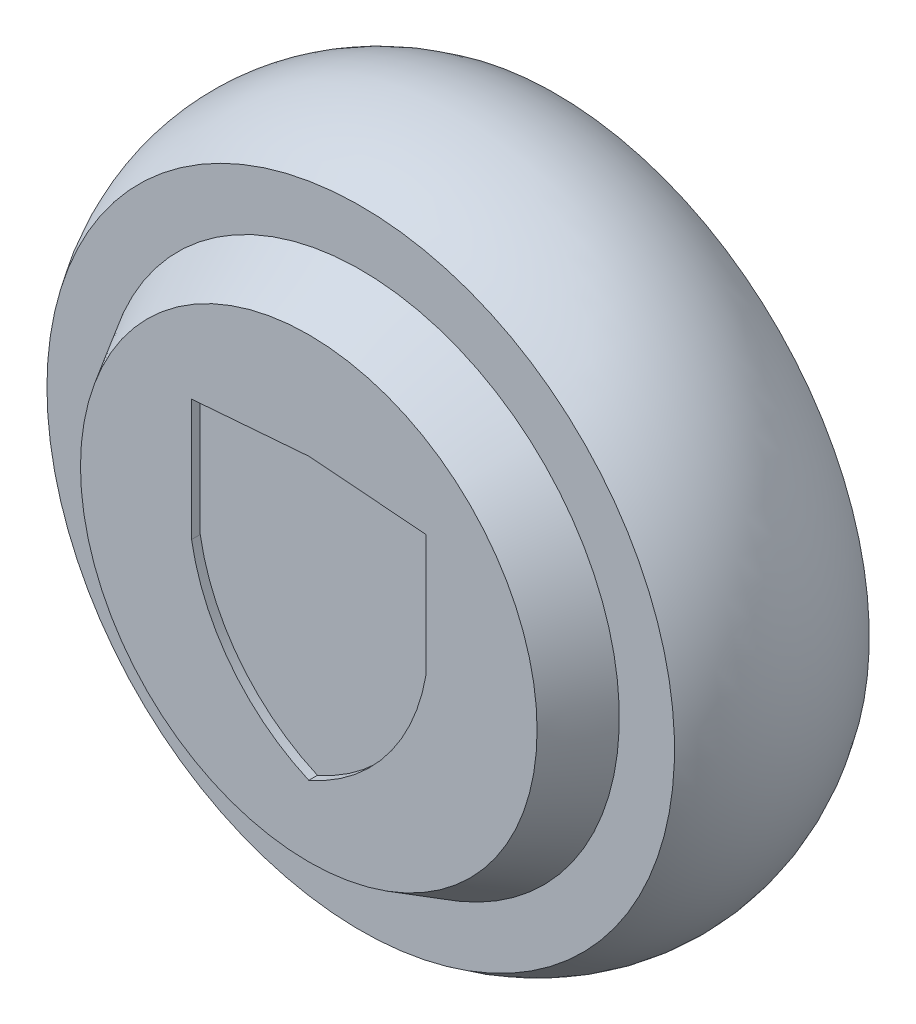
from build123d import *

# Parameters (mm, degrees)
EXTRUDE_1_DEPTH      = 22.5
EXTRUDE_1_DEPTH_BACK = 22.5
SKETCH_1_R           = 82.5
SKETCH_4_R           = 67.5
CUT_EXTRUDE_1_DEPTH  = 4
SKETCH_5_R           = 52
CUT_EXTRUDE_2_DEPTH  = 48
CUT_EXTRUDE_3_DEPTH  = 2


with BuildPart() as part:
    # Эскиз1 → Бобышка-Вытянуть1 (new, two sides: drawn at the far end of the back side and taken through both)
    with BuildSketch(Plane.XY.offset(-EXTRUDE_1_DEPTH_BACK)):
        Circle(SKETCH_1_R)
    extrude(amount=EXTRUDE_1_DEPTH + EXTRUDE_1_DEPTH_BACK)

    # Эскиз3 → Повернуть1 (revolve)
    with BuildSketch(Plane(origin=(0, 0, 0), x_dir=(0, 0, -1), z_dir=(1, 0, 0))):
        Polygon((-22.5, 0), (-22.5, 59.75), (-34.5, 52.75), (-34.5, 0), align=None)
    revolve(axis=Axis((0, 0, -22.110804518), (0, 0, 1)))

    # Эскиз4 → Вырез-Вытянуть1 (cut)
    with BuildSketch(Plane(origin=(0, 0, -22.5), x_dir=(-1, 0, 0), z_dir=(0, 0, -1))):
        Circle(SKETCH_4_R)
    extrude(amount=-CUT_EXTRUDE_1_DEPTH, mode=Mode.SUBTRACT)

    # Эскиз5 → Вырез-Вытянуть2 (cut)
    with BuildSketch(Plane(origin=(0, 0, -18.5), x_dir=(-1, 0, 0), z_dir=(0, 0, -1))):
        Circle(SKETCH_5_R)
    extrude(amount=-CUT_EXTRUDE_2_DEPTH, mode=Mode.SUBTRACT)

    # Эскиз7 → Вырез-Повернуть1 (revolve, cut)
    with BuildSketch(Plane(origin=(0, 0, 0), x_dir=(0, 0, -1), z_dir=(1, 0, 0))):
        with BuildLine():
            Line((-22.5, 72.5), (-31.948658462, 72.5))
            Line((-31.948658462, 72.5), (-31.948658462, 102.607455118))
            Line((-31.948658462, 102.607455118), (33.489916399, 102.607455118))
            Line((33.489916399, 102.607455118), (33.489916399, 72.5))
            Line((33.489916399, 72.5), (22.5, 72.5))
            ThreePointArc((22.5, 72.5), (0, 79.75), (-22.5, 72.5))
        make_face()
    revolve(axis=Axis((0, 0, 0), (0, 0, 1)), mode=Mode.SUBTRACT)

    # Эскиз8 → Вырез-Вытянуть3 (cut)
    with BuildSketch(Plane.XY.offset(34.5)):
        with BuildLine():
            Line((-27.080041081, 26.318414926), (0, 28.434043135))
            Line((0, 28.434043135), (27.080041081, 26.318414926))
            Line((27.080041081, 26.318414926), (27.080041081, -1.78158165))
            ThreePointArc((27.080041081, -1.78158165), (17.912944533, -22.517713966), (0, -36.415528927))
            ThreePointArc((0, -36.415528927), (-17.912944533, -22.517713966), (-27.080041081, -1.78158165))
            Line((-27.080041081, -1.78158165), (-27.080041081, 26.318414926))
        make_face()
    extrude(amount=-CUT_EXTRUDE_3_DEPTH, mode=Mode.SUBTRACT)


solid = part.part
